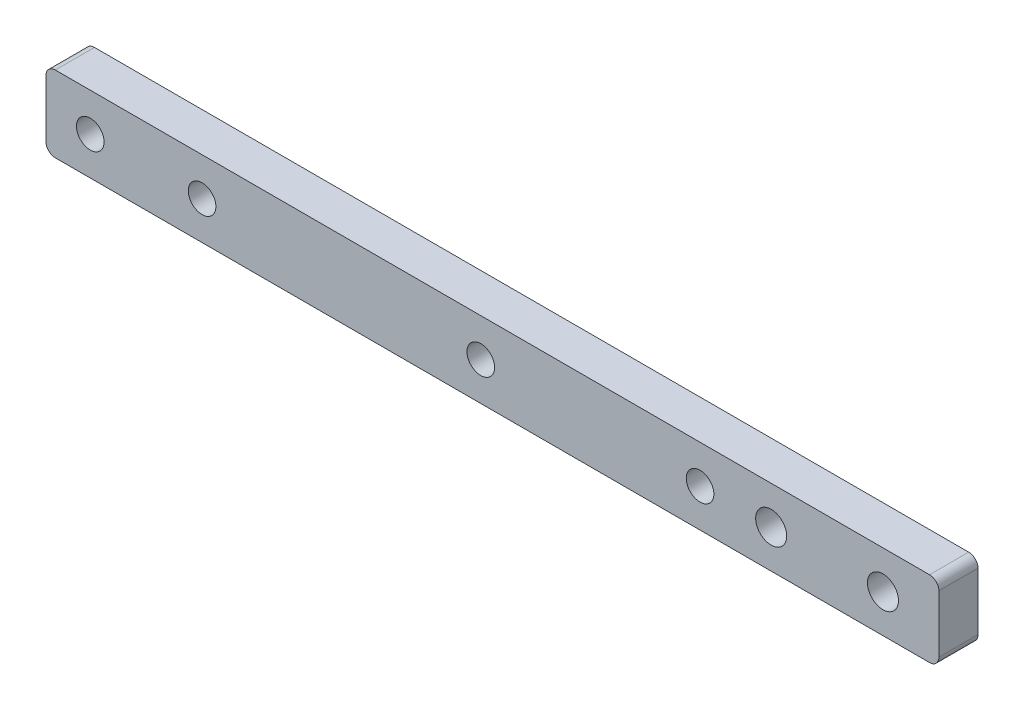
from build123d import *

# Parameters (mm, degrees)
SKETCH1_W           = 73.025
SKETCH1_H           = 6.223
SKETCH1_R           = 1.27
SKETCH1_R_2         = 1.1303
BOSS_EXTRUDE1_DEPTH = 3.2004
SKETCH2_R           = 1.1303
CUT_EXTRUDE1_DEPTH  = 3.2004
FILLET1_R           = 0.762


with BuildPart() as part:
    # Sketch1 → Boss-Extrude1 (new body)
    with BuildSketch(Plane.XY):
        with Locations((36.5125, 3.1115)):
            Rectangle(SKETCH1_W, SKETCH1_H)
        with Locations((59.309, 3.1115)):
            Circle(SKETCH1_R, mode=Mode.SUBTRACT)
        with Locations((68.453, 3.1115)):
            Circle(SKETCH1_R, mode=Mode.SUBTRACT)
        with Locations((3.6195, 3.1115)):
            Circle(SKETCH1_R_2, mode=Mode.SUBTRACT)
        with Locations((12.7635, 3.1115)):
            Circle(SKETCH1_R_2, mode=Mode.SUBTRACT)
    extrude(amount=BOSS_EXTRUDE1_DEPTH)

    # Sketch2 → Cut-Extrude1 (cut)
    with BuildSketch(Plane.XY.offset(3.2004)):
        with Locations((35.56, 3.1115)):
            Circle(SKETCH2_R)
        with Locations((53.4924, 3.1115)):
            Circle(SKETCH2_R)
    extrude(amount=-CUT_EXTRUDE1_DEPTH, mode=Mode.SUBTRACT)

    # Fillet1
    fillet1_edges = [part.edges().sort_by_distance(p)[0] for p in [
        (0, 6.223, 1.6002),
        (73.025, 6.223, 1.6002),
        (73.025, 0, 1.6002),
        (0, 0, 1.6002),
    ]]
    fillet(fillet1_edges, radius=FILLET1_R)


solid = part.part
